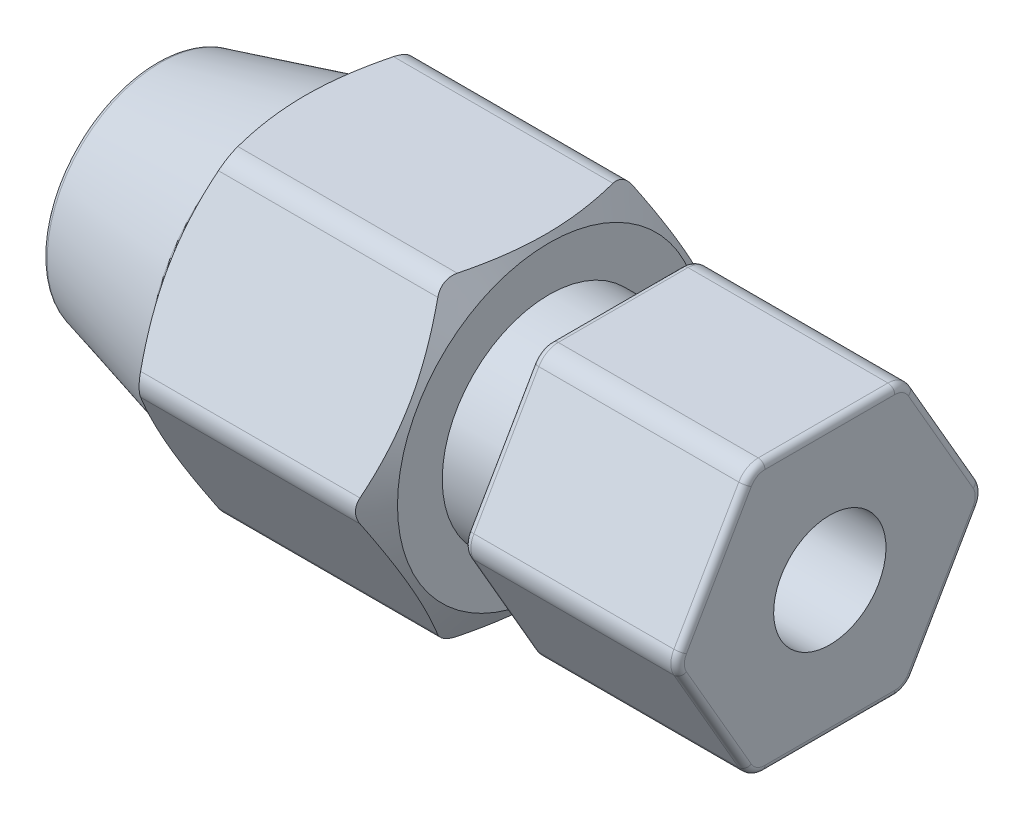
from build123d import *

# Parameters (mm, degrees)
SKETCH_2_R          = 12.5
CUT_EXTRUDE_1_DEPTH = 13.5
FILLET_1_R          = 1
SKETCH_3_R          = 12.5
CUT_EXTRUDE_2_DEPTH = 18.5
FILLET_2_R          = 0.3
FILLET_3_R          = 1
FILLET_4_R          = 0.15


with BuildPart() as part:
    # Эскиз1 → Повернуть1 (revolve)
    with BuildSketch(Plane.XY):
        Polygon((-30, 36.723884975), (0, 36.723884975), (0, 38.973884975), (0, 40), (0, 46.723884975), (-9.5, 46.723884975), (-9.5, 38.973884975), (-12.5, 38.973884975), (-12.5, 40.965554725), (-15.824573519, 46.723884975), (-20.175426481, 46.723884975), (-23.5, 40.965554725), (-30, 39.223884975), (-30, 38.473884975), (-27.5, 38.473884975), (-27.5, 37.692606633), (-30, 37.473884975), align=None)
    revolve(axis=Axis((0, 34.223884975, 0), (-1, 0, 0)))

    # Эскиз2 → Вырез-Вытянуть1 (cut, through all)
    with BuildSketch(Plane(origin=(-12.5, 0, 0), x_dir=(0, 0, -1), z_dir=(1, 0, 0))):
        with Locations((0, 34.223884975)):
            Circle(SKETCH_2_R)
        Polygon((3.464101615, 28.223884975), (6.92820323, 34.223884975), (3.464101615, 40.223884975), (-3.464101615, 40.223884975), (-6.92820323, 34.223884975), (-3.464101615, 28.223884975), align=None, mode=Mode.SUBTRACT)
    extrude(amount=CUT_EXTRUDE_1_DEPTH, mode=Mode.SUBTRACT)

    # Скругление1
    fillet_1_edges = [part.edges().sort_by_distance(p)[0] for p in [
        (-4.75, 28.223884975, -3.464101615),
        (-4.75, 34.223884975, -6.92820323),
        (-4.75, 40.223884975, -3.464101615),
        (-4.75, 40.223884975, 3.464101615),
        (-4.75, 34.223884975, 6.92820323),
        (-4.75, 28.223884975, 3.464101615),
    ]]
    fillet(fillet_1_edges, radius=FILLET_1_R)

    # Эскиз3 → Вырез-Вытянуть2 (cut, through all)
    with BuildSketch(Plane(origin=(-12.5, 0, 0), x_dir=(0, 0, -1), z_dir=(1, 0, 0))):
        with Locations((0, 34.223884975)):
            Circle(SKETCH_3_R)
        Polygon((-4.041451884, 27.223884975), (4.041451884, 27.223884975), (8.082903769, 34.223884975), (4.041451884, 41.223884975), (-4.041451884, 41.223884975), (-8.082903769, 34.223884975), align=None, mode=Mode.SUBTRACT)
    extrude(amount=-CUT_EXTRUDE_2_DEPTH, mode=Mode.SUBTRACT)

    # Скругление2
    fillet_2_edges = [part.edges().sort_by_distance(p)[0] for p in [
        (-30, 31.723884975, 0),
        (-30, 30.973884975, 0),
        (-30, 29.223884975, 0),
        (-23.5, 27.482215224, 0),
        (-9.5, 29.473884975, 0),
        (0, 37.223884975, -5.196152423),
        (-9.5, 37.223884975, -5.196152423),
        (-9.5, 31.223884975, -5.196152423),
        (-9.5, 28.223884975, 0),
        (-9.5, 31.223884975, 5.196152423),
        (-9.5, 37.223884975, 5.196152423),
        (-9.5, 40.223884975, 0),
        (-9.5, 40.089910378, 3.386751346),
        (-9.5, 40.089910378, -3.386751346),
        (-9.5, 34.223884975, 6.773502692),
        (-9.5, 28.357859571, 3.386751346),
        (-9.5, 28.357859571, -3.386751346),
        (-9.5, 34.223884975, -6.773502692),
        (0, 31.223884975, -5.196152423),
        (0, 31.223884975, 5.196152423),
        (0, 28.223884975, 0),
        (0, 40.223884975, 0),
        (0, 37.223884975, 5.196152423),
        (0, 40.089910378, 3.386751346),
        (0, 40.089910378, -3.386751346),
        (0, 34.223884975, 6.773502692),
        (0, 28.357859571, 3.386751346),
        (0, 28.357859571, -3.386751346),
        (0, 34.223884975, -6.773502692),
    ]]
    fillet(fillet_2_edges, radius=FILLET_2_R)

    # Скругление3
    fillet_3_edges = [part.edges().sort_by_distance(p)[0] for p in [
        (-18, 27.223884975, 4.041451884),
        (-18, 27.223884975, -4.041451884),
        (-18, 34.223884975, -8.082903769),
        (-18, 41.223884975, -4.041451884),
        (-18, 41.223884975, 4.041451884),
        (-18, 34.223884975, 8.082903769),
    ]]
    fillet(fillet_3_edges, radius=FILLET_3_R)

    # Скругление4
    fillet_4_edges = [part.edges().sort_by_distance(p)[0] for p in [
        (-30, 29.973884975, 0),
    ]]
    fillet(fillet_4_edges, radius=FILLET_4_R)


solid = part.part
